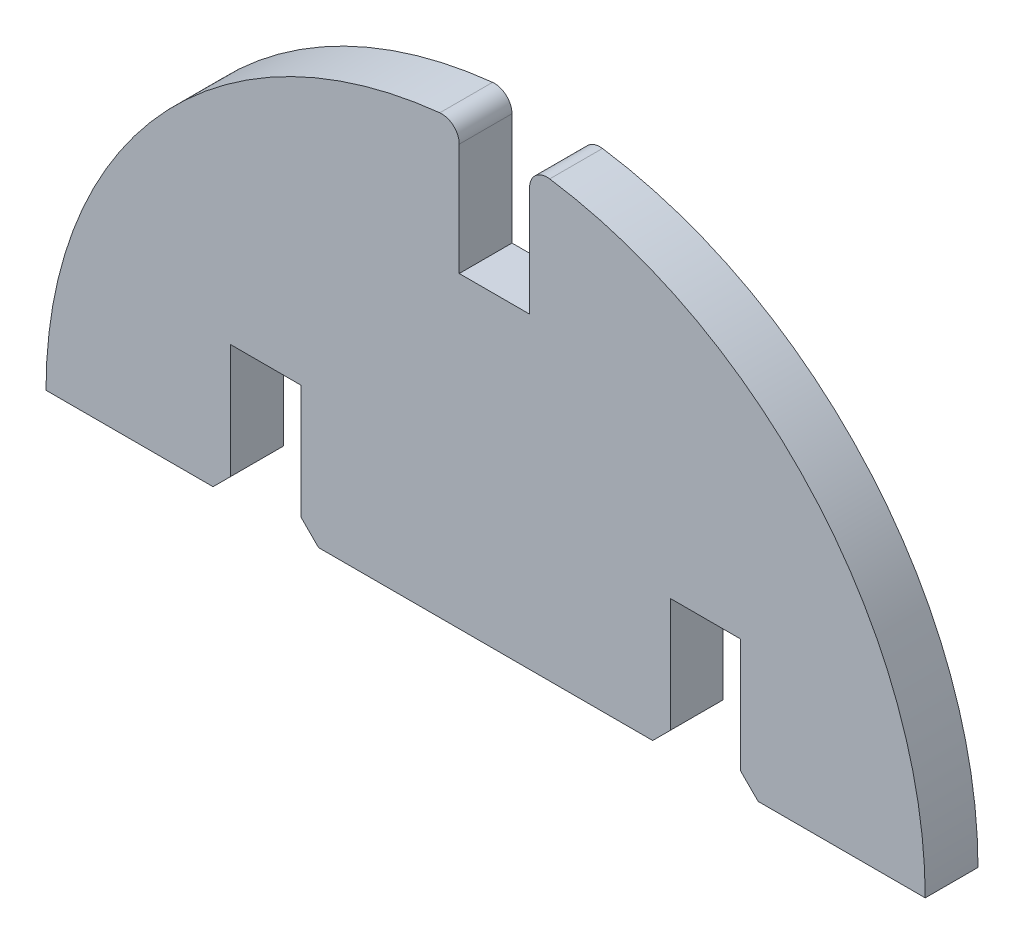
from build123d import *

# Parameters (mm, degrees)
BOSS_EXTRUDE1_DEPTH = 3


with BuildPart() as part:
    # Sketch1 → Boss-Extrude1 (new body)
    with BuildSketch(Plane.XY):
        with BuildLine():
            Line((-25, 0), (-15.5, 0))
            Line((-15.5, 0), (-14.5, 1))
            Line((-14.5, 1), (-14.5, 7.5))
            Line((-14.5, 7.5), (-10.5, 7.5))
            Line((-10.5, 7.5), (-10.5, 1))
            Line((-10.5, 1), (-9.5, 0))
            Line((-9.5, 0), (9.5, 0))
            Line((9.5, 0), (10.5, 1))
            Line((10.5, 1), (10.5, 7.5))
            Line((10.5, 7.5), (14.5, 7.5))
            Line((14.5, 7.5), (14.5, 1))
            Line((14.5, 1), (15.5, 0))
            Line((15.5, 0), (25, 0))
            ThreePointArc((25, 0), (18.922814713, 16.337903272), (3.645833333, 24.732729314))
            ThreePointArc((3.645833333, 24.732729314), (2.846483869, 24.50033273), (2.5, 23.743420141))
            Line((2.5, 23.743420141), (2.5, 17.5))
            Line((2.5, 17.5), (-1.5, 17.5))
            Line((-1.5, 17.5), (-1.5, 23.869436525))
            ThreePointArc((-1.5, 23.869436525), (-1.830734233, 24.612459629), (-2.604166667, 24.86399638))
            ThreePointArc((-2.604166667, 24.86399638), (-18.575577604, 16.731644171), (-25, 0))
        make_face()
    extrude(amount=BOSS_EXTRUDE1_DEPTH)


solid = part.part
